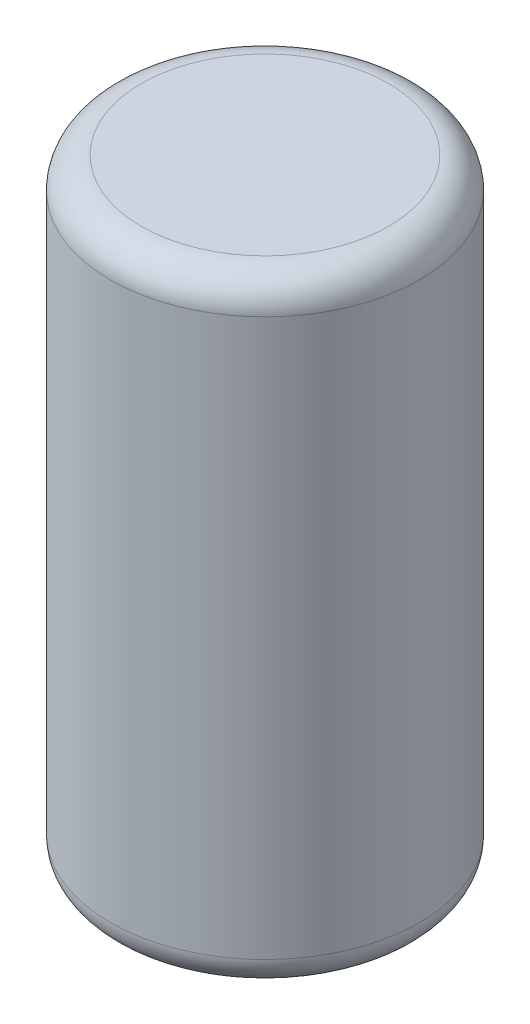
from build123d import *

# Parameters (mm, degrees)
SKETCH1_R           = 3.175
BOSS_EXTRUDE1_DEPTH = 12.7
FILLET1_R           = 0.635


with BuildPart() as part:
    # Sketch1 → Boss-Extrude1 (new body)
    with BuildSketch(Plane(origin=(0, 0, 0), x_dir=(1, 0, 0), z_dir=(0, 1, 0))):
        with Locations(Location((0, 0, 0), (0, 0, 270))):  # turned: the seam where the file's is
            Circle(SKETCH1_R)
    extrude(amount=BOSS_EXTRUDE1_DEPTH)

    # Fillet1
    fillet1_edges = [part.edges().sort_by_distance(p)[0] for p in [
        (0, 0, -3.175),
        (0, 12.7, -3.175),
    ]]
    fillet(fillet1_edges, radius=FILLET1_R)


solid = part.part
